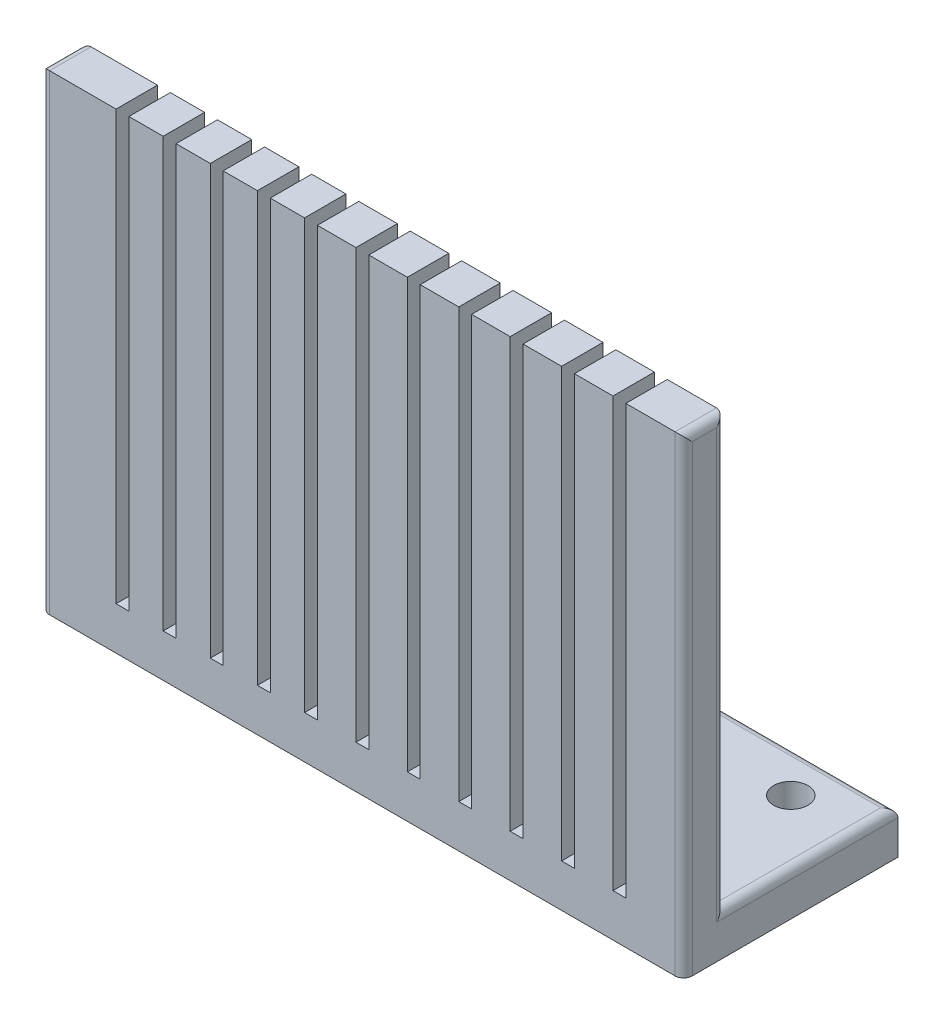
from build123d import *

# Parameters (mm, degrees)
SKETCH1_W           = 150
SKETCH1_H           = 50
SKETCH1_R           = 4
BOSS_EXTRUDE1_DEPTH = 10
SKETCH2_W           = 150
SKETCH2_H           = 9.667678079
BOSS_EXTRUDE2_DEPTH = 100
SKETCH3_W           = 3
SKETCH3_H           = 100
CUT_EXTRUDE1_DEPTH  = 100
FILLET1_R           = 2


with BuildPart() as part:
    # Sketch1 → Boss-Extrude1 (new body)
    with BuildSketch(Plane(origin=(0, 0, 0), x_dir=(1, 0, 0), z_dir=(0, 1, 0))):
        Rectangle(SKETCH1_W, SKETCH1_H)
        with Locations((60, 15)):
            Circle(SKETCH1_R, mode=Mode.SUBTRACT)
        with Locations((-60, 15)):
            Circle(SKETCH1_R, mode=Mode.SUBTRACT)
    extrude(amount=BOSS_EXTRUDE1_DEPTH)

    # Sketch2 → Boss-Extrude2 (add)
    with BuildSketch(Plane(origin=(0, 10, 0), x_dir=(1, 0, 0), z_dir=(0, 1, 0))):
        with Locations((0, -20.166160961)):
            Rectangle(SKETCH2_W, SKETCH2_H)
    extrude(amount=BOSS_EXTRUDE2_DEPTH)

    # Sketch3 → Cut-Extrude1 (cut)
    with BuildSketch(Plane(origin=(0, 0, 15.332321921), x_dir=(-1, 0, 0), z_dir=(0, 0, -1))):
        with Locations((-12, 60)):
            Rectangle(SKETCH3_W, SKETCH3_H)
        with Locations((0, 60)):
            Rectangle(SKETCH3_W, SKETCH3_H)
        with Locations((12, 60)):
            Rectangle(SKETCH3_W, SKETCH3_H)
        with Locations((23, 60)):
            Rectangle(SKETCH3_W, SKETCH3_H)
        with Locations((34, 60)):
            Rectangle(SKETCH3_W, SKETCH3_H)
        with Locations((45, 60)):
            Rectangle(SKETCH3_W, SKETCH3_H)
        with Locations((56, 60)):
            Rectangle(SKETCH3_W, SKETCH3_H)
        with Locations((-24, 60)):
            Rectangle(SKETCH3_W, SKETCH3_H)
        with Locations((-36, 60)):
            Rectangle(SKETCH3_W, SKETCH3_H)
        with Locations((-48, 60)):
            Rectangle(SKETCH3_W, SKETCH3_H)
        with Locations((-60, 60)):
            Rectangle(SKETCH3_W, SKETCH3_H)
    extrude(amount=-CUT_EXTRUDE1_DEPTH, mode=Mode.SUBTRACT)

    # Fillet1
    fillet1_edges = [part.edges().sort_by_distance(p)[0] for p in [
        (0, 10, -25),
        (75, 10, -4.83383904),
        (-75, 60, 15.332321921),
        (75, 60, 15.332321921),
        (-75, 110, 20.16616096),
        (75, 110, 20.16616096),
        (-75, 10, -4.83383904),
        (75, 55, 25),
        (-75, 55, 25),
    ]]
    fillet(fillet1_edges, radius=FILLET1_R)


solid = part.part
